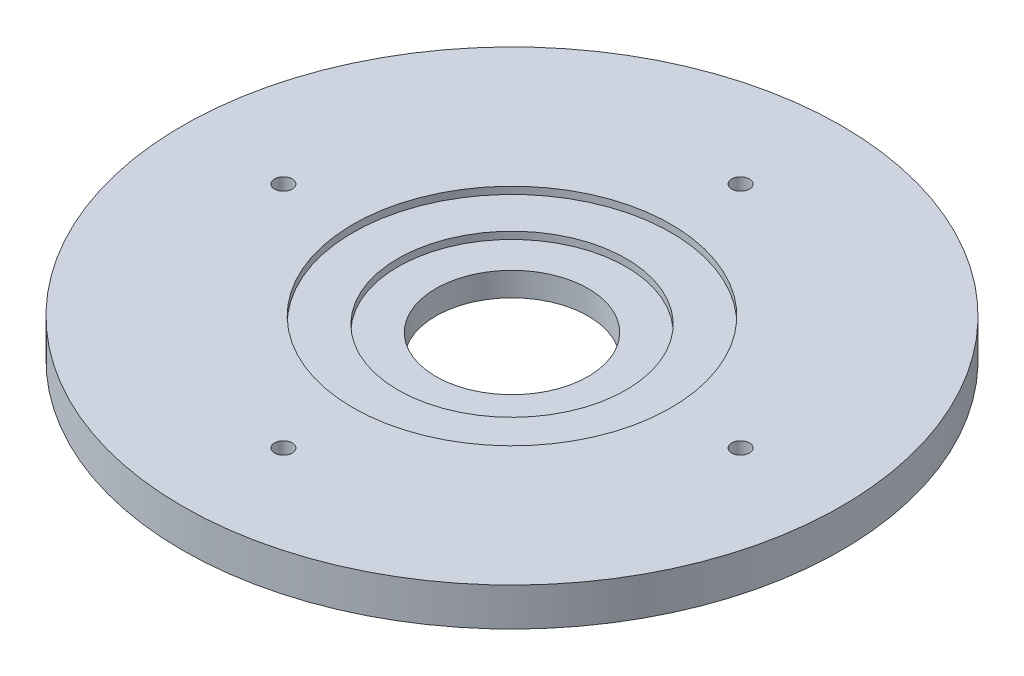
from build123d import *

# Parameters (mm, degrees)
SKETCH1_R           = 54.9275
SKETCH1_R_2         = 12.7
BOSS_EXTRUDE1_DEPTH = 6.35
SKETCH2_R           = 26.5
CUT_EXTRUDE1_DEPTH  = 1.190625
SKETCH3_R           = 19
CUT_EXTRUDE2_DEPTH  = 2.38125
SKETCH4_R           = 1.4732
CUT_EXTRUDE3_DEPTH  = 7.35


with BuildPart() as part:
    # Sketch1 → Boss-Extrude1 (new body)
    with BuildSketch(Plane(origin=(0, 0, 0), x_dir=(1, 0, 0), z_dir=(0, 1, 0))):
        with Locations(Location((0, 0, 0), (0, 0, 270))):  # turned: the seam where the file's is
            Circle(SKETCH1_R)
        with Locations(Location((0, 0, 0), (0, 0, 270))):  # turned: the seam where the file's is
            Circle(SKETCH1_R_2, mode=Mode.SUBTRACT)
    extrude(amount=BOSS_EXTRUDE1_DEPTH)

    # Sketch2 → Cut-Extrude1 (cut)
    with BuildSketch(Plane(origin=(0, 6.35, 0), x_dir=(1, 0, 0), z_dir=(0, 1, 0))):
        with Locations(Location((0, 0, 0), (0, 0, 270))):  # turned: the seam where the file's is
            Circle(SKETCH2_R)
    extrude(amount=-CUT_EXTRUDE1_DEPTH, mode=Mode.SUBTRACT)

    # Sketch3 → Cut-Extrude2 (cut)
    with BuildSketch(Plane(origin=(0, 6.35, 0), x_dir=(1, 0, 0), z_dir=(0, 1, 0))):
        with Locations(Location((0, 0, 0), (0, 0, 270))):  # turned: the seam where the file's is
            Circle(SKETCH3_R)
    extrude(amount=-CUT_EXTRUDE2_DEPTH, mode=Mode.SUBTRACT)

    # Sketch4 → Cut-Extrude3 (cut, through all)
    with BuildSketch(Plane(origin=(0, 6.35, 0), x_dir=(-1, 0, 0), z_dir=(0, 1, 0))):
        with Locations(Location((-38.1, 0, 0), (0, 0, 90))):  # turned: the seam where the file's is
            Circle(SKETCH4_R)
        with Locations(Location((0, -38.1, 0), (0, 0, 90))):  # turned: the seam where the file's is
            Circle(SKETCH4_R)
        with Locations(Location((38.1, 0, 0), (0, 0, 90))):  # turned: the seam where the file's is
            Circle(SKETCH4_R)
        with Locations(Location((0, 38.1, 0), (0, 0, 90))):  # turned: the seam where the file's is
            Circle(SKETCH4_R)
    extrude(amount=-CUT_EXTRUDE3_DEPTH, mode=Mode.SUBTRACT)


solid = part.part
